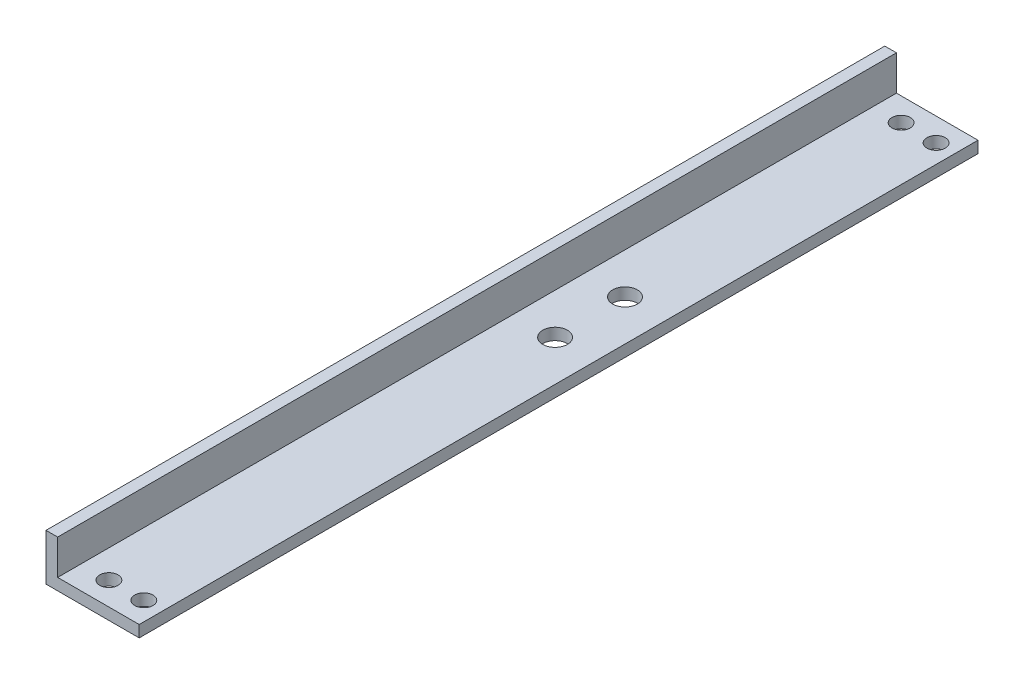
from build123d import *

# Parameters (mm, degrees)
BOSS_EXTRUDE1_DEPTH = 228.6
SKETCH2_R           = 2.4892
CUT_EXTRUDE1_DEPTH  = 4.175
SKETCH3_W           = 228.6
SKETCH3_H           = 12.7
CUT_EXTRUDE2_DEPTH  = 4.175
SKETCH4_R           = 3.3655
CUT_EXTRUDE3_DEPTH  = 4.175


with BuildPart() as part:
    # Sketch1 → Boss-Extrude1 (new body)
    with BuildSketch(Plane.XY):
        Polygon((0, 0), (0, 25.4), (3.175, 25.4), (3.175, 3.175), (25.4, 3.175), (25.4, 0), align=None)
    extrude(amount=BOSS_EXTRUDE1_DEPTH)

    # Sketch2 → Cut-Extrude1 (cut, through all)
    with BuildSketch(Plane(origin=(0, 3.175, 0), x_dir=(1, 0, 0), z_dir=(0, 1, 0))):
        with Locations((20.32, -222.25)):
            Circle(SKETCH2_R)
        with Locations((10.795, -222.25)):
            Circle(SKETCH2_R)
        with Locations((20.32, -6.35)):
            Circle(SKETCH2_R)
        with Locations((10.795, -6.35)):
            Circle(SKETCH2_R)
    extrude(amount=-CUT_EXTRUDE1_DEPTH, mode=Mode.SUBTRACT)

    # Sketch3 → Cut-Extrude2 (cut, through all)
    with BuildSketch(Plane(origin=(3.175, 0, 0), x_dir=(0, 0, -1), z_dir=(1, 0, 0))):
        with Locations((-114.3, 19.05)):
            Rectangle(SKETCH3_W, SKETCH3_H)
    extrude(amount=-CUT_EXTRUDE2_DEPTH, mode=Mode.SUBTRACT)

    # Sketch4 → Cut-Extrude3 (cut, through all)
    with BuildSketch(Plane(origin=(0, 3.175, 0), x_dir=(1, 0, 0), z_dir=(0, 1, 0))):
        with Locations((14.2875, -85.09)):
            Circle(SKETCH4_R)
        with Locations((14.2875, -104.14)):
            Circle(SKETCH4_R)
    extrude(amount=-CUT_EXTRUDE3_DEPTH, mode=Mode.SUBTRACT)


solid = part.part
